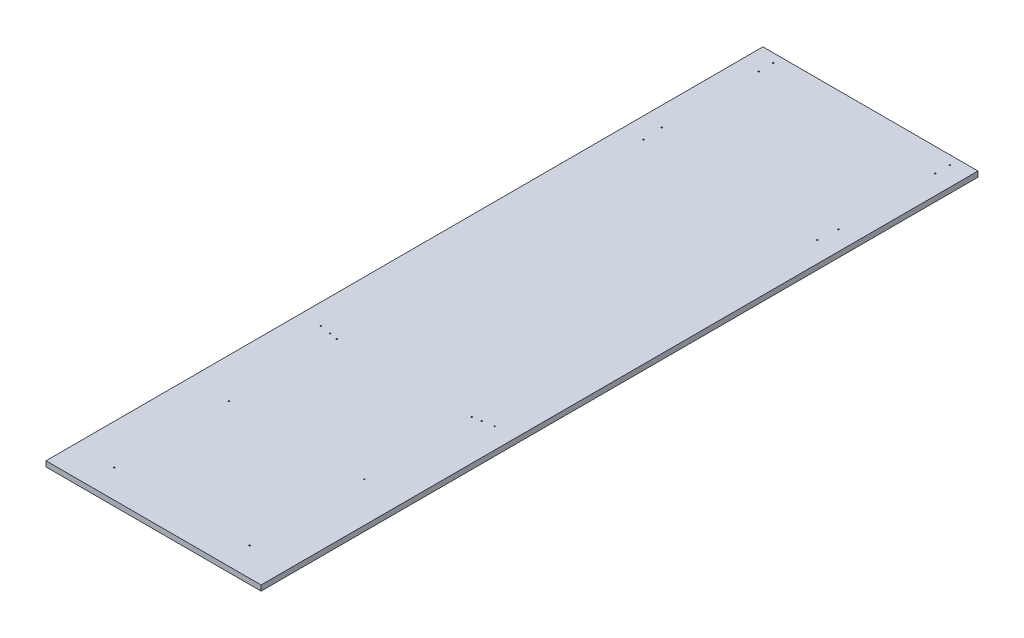
from build123d import *

# Parameters (mm, degrees)
SKETCH1_W           = 600
SKETCH1_H           = 2000
SKETCH1_R           = 1.75
BOSS_EXTRUDE1_DEPTH = 15


with BuildPart() as part:
    # Sketch1 → Boss-Extrude1 (new body)
    with BuildSketch(Plane(origin=(0, 0, 0), x_dir=(1, 0, 0), z_dir=(0, 1, 0))):
        Rectangle(SKETCH1_W, SKETCH1_H)
        with Locations((-188.5, -920.710678119)):
            Circle(SKETCH1_R, mode=Mode.SUBTRACT)
        with Locations((188.5, -920.710678119)):
            Circle(SKETCH1_R, mode=Mode.SUBTRACT)
        with Locations((188.5, -600.710678119)):
            Circle(SKETCH1_R, mode=Mode.SUBTRACT)
        with Locations((-188.5, -300.710678119)):
            Circle(SKETCH1_R, mode=Mode.SUBTRACT)
        with Locations((-188.5, -600.710678119)):
            Circle(SKETCH1_R, mode=Mode.SUBTRACT)
        with Locations((188.5, -300.710678119)):
            Circle(SKETCH1_R, mode=Mode.SUBTRACT)
        with Locations((-211.5, -295.710678119)):
            Circle(SKETCH1_R, mode=Mode.SUBTRACT)
        with Locations((211.5, -295.710678119)):
            Circle(SKETCH1_R, mode=Mode.SUBTRACT)
        with Locations((-242.5, -290.710678119)):
            Circle(SKETCH1_R, mode=Mode.SUBTRACT)
        with Locations((-242.5, 609.289321881)):
            Circle(SKETCH1_R, mode=Mode.SUBTRACT)
        with Locations((242.5, -290.710678119)):
            Circle(SKETCH1_R, mode=Mode.SUBTRACT)
        with Locations((242.5, 609.289321881)):
            Circle(SKETCH1_R, mode=Mode.SUBTRACT)
        with Locations((246.5, 664.289321881)):
            Circle(SKETCH1_R, mode=Mode.SUBTRACT)
        with Locations((-246.5, 664.289321881)):
            Circle(SKETCH1_R, mode=Mode.SUBTRACT)
        with Locations((-246.5, 934.289321881)):
            Circle(SKETCH1_R, mode=Mode.SUBTRACT)
        with Locations((-246.5, 975)):
            Circle(SKETCH1_R, mode=Mode.SUBTRACT)
        with Locations((246.5, 934.289321881)):
            Circle(SKETCH1_R, mode=Mode.SUBTRACT)
        with Locations((246.5, 975)):
            Circle(SKETCH1_R, mode=Mode.SUBTRACT)
    extrude(amount=BOSS_EXTRUDE1_DEPTH)


solid = part.part
